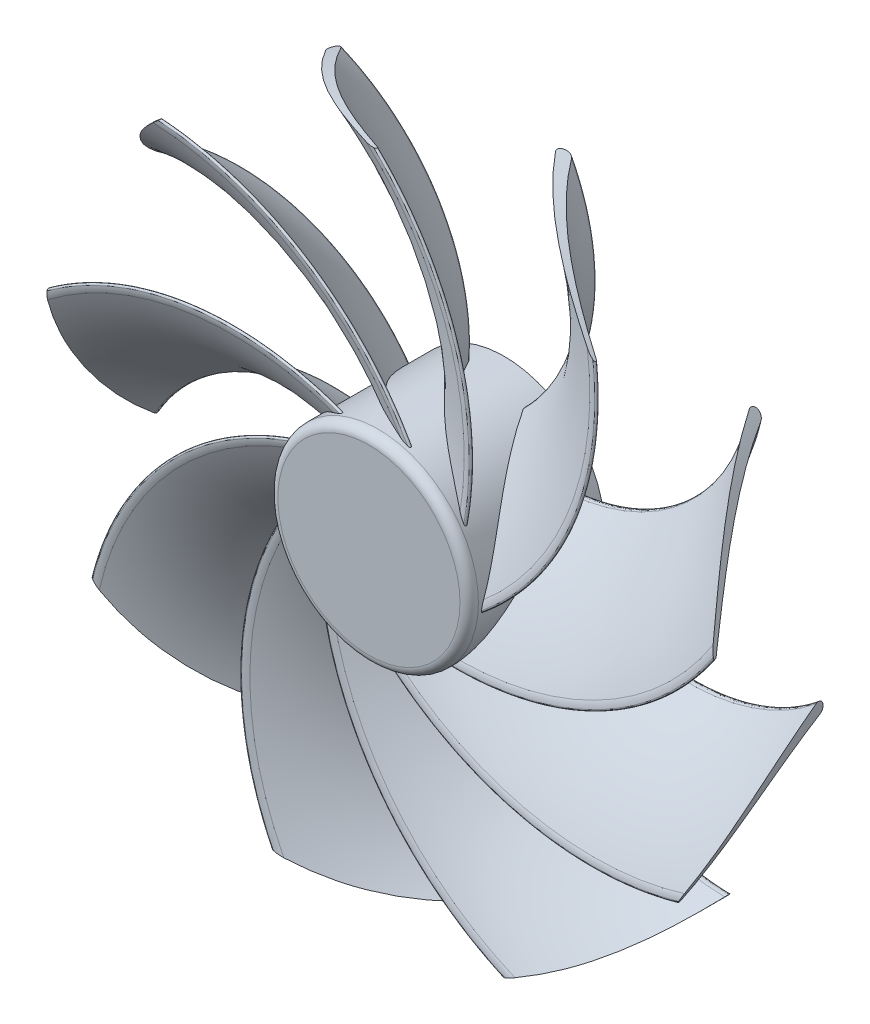
from build123d import *

# Parameters (mm, degrees)
SKETCH1_R           = 16.3
BOSS_EXTRUDE1_DEPTH = 22
FILLET1_R           = 1.5
CIRPATTERN1_COUNT   = 9
SKETCH5_R           = 98.634415399
SKETCH5_R_2         = 55.00556085
CUT_EXTRUDE2_DEPTH  = 23.0000001


with BuildPart() as part:
    # Sketch1 → Boss-Extrude1 (new body)
    with BuildSketch(Plane.XY):
        Circle(SKETCH1_R)
    extrude(amount=BOSS_EXTRUDE1_DEPTH)

    # Fillet1
    fillet1_edges = [part.edges().sort_by_distance(p)[0] for p in [
        (-16.3, 0, 22),
    ]]
    fillet(fillet1_edges, radius=FILLET1_R)

    # Sweep1: sweep along a path in Sketch4
    with BuildLine(Plane(origin=(0, 0, 9.5), x_dir=(-0.979796148, -0.199998772, 0), z_dir=(0, 0, 1))) as sweep1_path:
        ThreePointArc((8.1338333, 0), (19.71488054, -23.969942103), (45.296607476, -31.335675369))
    # Sketch2 → Sweep1 (sweep)
    with BuildSketch(Plane(origin=(0, 0, 9.5), x_dir=(-0.979796148, -0.199998772, 0), z_dir=(0.199998772, -0.979796148, 0))):
        with BuildLine():
            ThreePointArc((-9.872751681, -10.022263724), (-0.308573655, -3.287214366), (6.739923763, 6.048366779))
            ThreePointArc((6.739923763, 6.048366779), (7.838981931, 6.367781689), (8.1338333, 5.261880513))
            ThreePointArc((8.1338333, 5.261880513), (0.861100777, -3.689089787), (-8.684864389, -10.161110857))
            ThreePointArc((-8.684864389, -10.161110857), (-9.209322634, -10.354004668), (-9.761132903, -10.442151706))
            ThreePointArc((-9.761132903, -10.442151706), (-9.988872618, -10.277911935), (-9.872751681, -10.022263724))
        make_face()
    sweep1 = sweep(path=sweep1_path.line)

    # CirPattern1: Sweep1 ×9 about axis
    cirpattern1_axis = Axis((0, 0, 22), (0, 0, 1))
    for i in range(1, CIRPATTERN1_COUNT):
        add(sweep1.rotate(cirpattern1_axis, i * 360 / CIRPATTERN1_COUNT))

    # Sketch5 → Cut-Extrude2 (cut, through all)
    with BuildSketch(Plane.XY.offset(22)):
        Circle(SKETCH5_R)
        Circle(SKETCH5_R_2, mode=Mode.SUBTRACT)
    extrude(amount=-CUT_EXTRUDE2_DEPTH, mode=Mode.SUBTRACT)


solid = part.part
